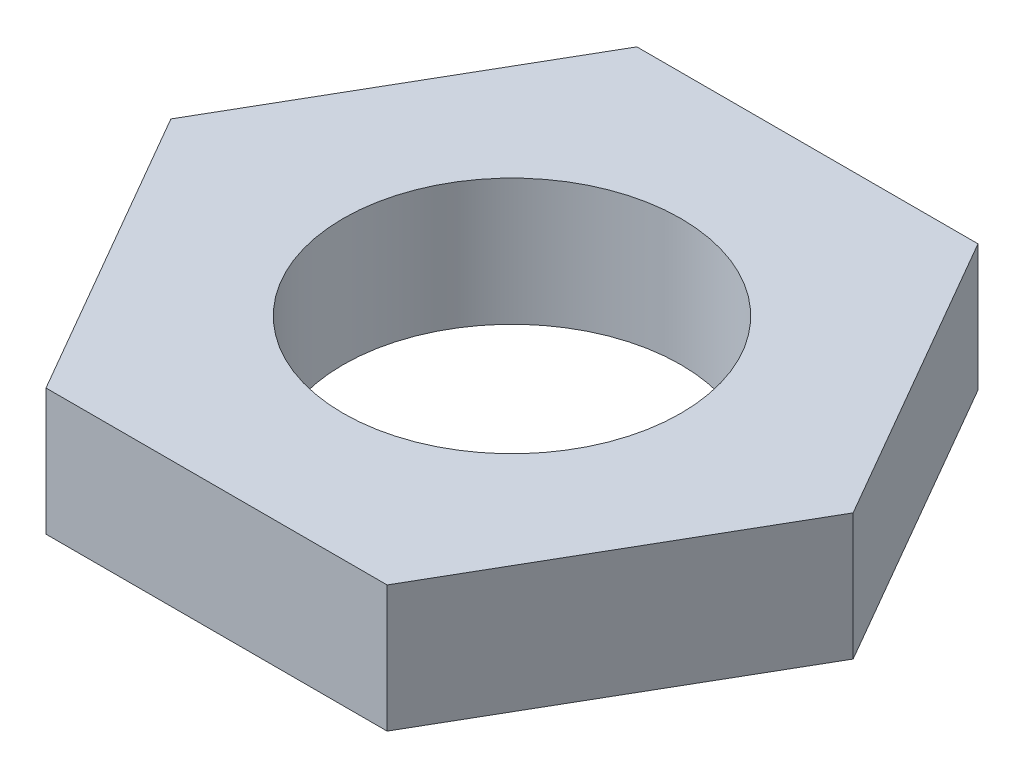
from build123d import *

# Parameters (mm, degrees)
SKETCH1_R           = 20
BOSS_EXTRUDE1_DEPTH = 15


with BuildPart() as part:
    # Sketch1 → Boss-Extrude1 (new body)
    with BuildSketch(Plane(origin=(0, 0, 0), x_dir=(1, 0, 0), z_dir=(0, 1, 0))):
        Polygon((-20.207259422, 35), (-40.414518843, 0), (-20.207259422, -35), (20.207259422, -35), (40.414518843, 0), (20.207259422, 35), align=None)
        Circle(SKETCH1_R, mode=Mode.SUBTRACT)
    extrude(amount=BOSS_EXTRUDE1_DEPTH)


solid = part.part
